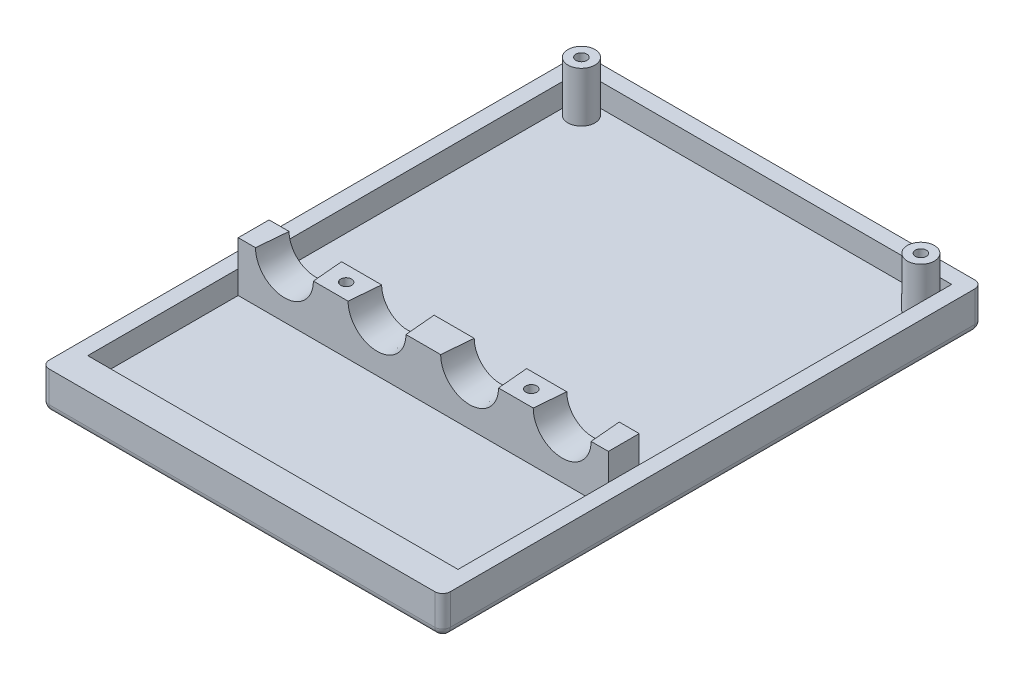
from build123d import *

# Parameters (mm, degrees)
SKETCH1_W                      = 82.55
SKETCH1_H                      = 111.125
BOSS_EXTRUDE1_DEPTH            = 7.9375
SKETCH3_W                      = 76.2
SKETCH3_H                      = 101.6
CUT_EXTRUDE1_DEPTH             = 4.7625
SKETCH4_R                      = 2.778125
SKETCH4_W                      = 76.2
SKETCH4_H                      = 6.35
BOSS_EXTRUDE2_DEPTH            = 4.7625
SKETCH5_R                      = 2.778125
SKETCH5_W                      = 76.1746
SKETCH5_H                      = 6.35
BOSS_EXTRUDE3_DEPTH            = 5.5499
SKETCH7_R                      = 5.953125
CUT_EXTRUDE2_DEPTH             = 6.35
CUT_EXTRUDE2_TAPER             = 5
FILLET1_R                      = 1.5875
SKETCH9_W                      = 0.693032722
SKETCH9_H                      = 1.166839696
CUT_EXTRUDE6_DEPTH             = 0.79375
SKETCH10_W                     = 1.300636175
SKETCH10_H                     = 0.609288305
BOSS_EXTRUDE10_DEPTH           = 0.79375
SKETCH10_W_2                   = 1.290786677
SKETCH10_H_2                   = 0.635299333
BOSS_EXTRUDE10_2_DEPTH         = 0.79375
SKETCH10_W_3                   = 0.590635344
SKETCH10_H_3                   = 1.200906415
BOSS_EXTRUDE10_3_DEPTH         = 0.79375
SKETCH10_W_4                   = 0.595847513
SKETCH10_H_4                   = 0.630493571
BOSS_EXTRUDE10_4_DEPTH         = 0.79375
F_4_40_TAPPED_HOLE4_AT_2_COUNT = 2
F_4_40_TAPPED_HOLE4_AT_2_PITCH = 38.1
F_4_40_TAPPED_HOLE4_AT_3_COUNT = 2
F_4_40_TAPPED_HOLE4_AT_3_PITCH = 83.946333536
F_4_40_TAPPED_HOLE4_AT_4_COUNT = 2
F_4_40_TAPPED_HOLE4_AT_4_PITCH = 66.22463223


with BuildPart() as part:
    # Sketch1 → Boss-Extrude1 (new body)
    with BuildSketch(Plane(origin=(0, 0, 0), x_dir=(1, 0, 0), z_dir=(0, 1, 0))):
        Rectangle(SKETCH1_W, SKETCH1_H)
    extrude(amount=BOSS_EXTRUDE1_DEPTH)

    # Sketch3 → Cut-Extrude1 (cut)
    with BuildSketch(Plane(origin=(0, 7.9375, 0), x_dir=(-1, 0, 0), z_dir=(0, 1, 0))):
        with Locations((0, -1.5875)):
            Rectangle(SKETCH3_W, SKETCH3_H)
    extrude(amount=-CUT_EXTRUDE1_DEPTH, mode=Mode.SUBTRACT)

    # Sketch4 → Boss-Extrude2 (add)
    with BuildSketch(Plane(origin=(0, 3.175, 0), x_dir=(-1, 0, 0), z_dir=(0, 1, 0))):
        with Locations((34.925, -49.2125)):
            Circle(SKETCH4_R)
        with Locations((-34.925, -49.2125)):
            Circle(SKETCH4_R)
        with Locations((0, 15.08125)):
            Rectangle(SKETCH4_W, SKETCH4_H)
    extrude(amount=BOSS_EXTRUDE2_DEPTH)

    # Sketch5 → Boss-Extrude3 (add)
    with BuildSketch(Plane(origin=(0, 7.9375, 0), x_dir=(-1, 0, 0), z_dir=(0, 1, 0))):
        with Locations((34.925, -49.2125)):
            Circle(SKETCH5_R)
        with Locations((-34.925, -49.2125)):
            Circle(SKETCH5_R)
        with Locations((0, 15.08125)):
            Rectangle(SKETCH5_W, SKETCH5_H)
    extrude(amount=BOSS_EXTRUDE3_DEPTH)

    # Sketch7 → Cut-Extrude2 (cut)
    with BuildSketch(Plane.XY.offset(18.25625)):
        with Locations((-28.575, 13.4874)):
            Circle(SKETCH7_R)
        with Locations((-9.525, 13.4874)):
            Circle(SKETCH7_R)
        with Locations((9.525, 13.4874)):
            Circle(SKETCH7_R)
        with Locations((28.575, 13.4874)):
            Circle(SKETCH7_R)
    extrude(amount=-CUT_EXTRUDE2_DEPTH, taper=CUT_EXTRUDE2_TAPER, mode=Mode.SUBTRACT)

    # Fillet1
    fillet1_edges = [part.edges().sort_by_distance(p)[0] for p in [
        (0, 0, 55.5625),
        (-41.275, 0, 0),
        (0, 0, -55.5625),
        (41.275, 0, 0),
        (41.275, 3.96875, 55.5625),
        (-41.275, 3.96875, 55.5625),
        (-41.275, 3.96875, -55.5625),
        (41.275, 3.96875, -55.5625),
    ]]
    fillet(fillet1_edges, radius=FILLET1_R)

    # Sketch9 → Cut-Extrude6 (cut)
    with BuildSketch(Plane.XZ):
        Polygon((-19.871599205, 50.060948489), (-23.378660117, 50.060948489), (-23.378660117, 49.462991256), (-24.789045709, 49.462991256), (-24.789045709, 50.060948489), (-28.298105511, 50.060948489), (-28.298105511, 49.462991256), (-30.146692, 49.462991256), (-30.146692, 48.220366501), (-30.824259295, 48.220366501), (-30.824259295, 47.536075665), (-31.942026377, 47.536075665), (-31.942026377, 46.362512428), (-32.668484568, 46.362512428), (-32.668484568, 45.726930772), (-33.201923216, 45.726930772), (-33.201923216, 43.240218584), (-33.777165784, 43.240218584), (-33.777165784, 42.020126776), (-36.257517866, 42.020126776), (-36.257517866, 41.524130834), (-36.88782972, 41.524130834), (-36.88782972, 37.820052598), (-36.257517866, 37.820052598), (-36.257517866, 37.33532313), (-34.485815679, 37.33532313), (-34.485815679, 32.3250012), (-33.777165784, 32.3250012), (-33.777165784, 31.694507629), (-33.201923216, 31.694507629), (-33.201923216, 30.527667933), (-31.942026377, 30.527667933), (-31.942026377, 29.314299666), (-32.571974796, 29.314299666), (-32.571974796, 27.461170243), (-33.201923216, 27.461170243), (-33.201923216, 26.338133359), (-30.824259295, 26.338133359), (-30.824259295, 27.469347523), (-30.146692, 27.469347523), (-30.146692, 28.091746255), (-29.598741686, 28.091746255), (-29.598741686, 27.469347523), (-28.909041959, 27.469347523), (-28.909041959, 26.903740441), (-28.298105511, 26.903740441), (-28.298105511, 25.633141775), (-25.910537024, 25.633141775), (-25.910537024, 25.075738158), (-22.795572643, 25.075738158), (-22.795572643, 25.633141775), (-20.371967068, 25.633141775), (-20.371967068, 26.268441108), (-19.871599205, 26.268441108), (-19.871599205, 26.903740441), (-19.082474376, 26.903740441), (-19.082474376, 27.469347523), (-17.993013222, 27.469347523), (-17.993013222, 26.268441108), (-16.088645027, 26.268441108), (-16.088645027, 29.314299666), (-16.665655943, 29.314299666), (-16.665655943, 30.527667933), (-14.850892856, 30.527667933), (-14.850892856, 32.3250012), (-14.251854017, 32.3250012), (-14.251854017, 35.994775983), (-13.658395717, 35.994775983), (-13.658395717, 37.33532313), (-11.8843629, 37.33532313), (-11.8843629, 37.820052598), (-11.280195998, 37.820052598), (-11.280195998, 41.524130834), (-11.8843629, 41.524130834), (-11.8843629, 42.020126776), (-14.251854017, 42.020126776), (-14.251854017, 43.240218584), (-14.850892856, 43.240218584), (-14.850892856, 45.726930772), (-15.433476892, 45.726930772), (-15.433476892, 46.362512428), (-16.088645027, 46.362512428), (-16.088645027, 47.536075665), (-17.299980501, 47.536075665), (-17.299980501, 48.220366501), (-17.993013222, 48.220366501), (-17.993013222, 49.462991256), (-19.871599205, 49.462991256), align=None)
        Polygon((-16.665655943, 42.663637575), (-17.993013222, 42.663637575), (-17.993013222, 43.240218584), (-19.871599205, 43.240218584), (-19.871599205, 43.83259077), (-21.599961018, 43.83259077), (-21.599961018, 43.240218584), (-22.204937299, 43.240218584), (-22.204937299, 42.663637575), (-22.795572643, 42.663637575), (-22.795572643, 41.524130834), (-25.230484206, 41.524130834), (-25.230484206, 42.663637575), (-25.910537024, 42.663637575), (-25.910537024, 43.240218584), (-26.562769367, 43.240218584), (-26.562769367, 43.83259077), (-28.298105511, 43.83259077), (-28.298105511, 43.240218584), (-30.146692, 43.240218584), (-30.146692, 42.663637575), (-31.444814914, 42.663637575), (-31.444814914, 41.524130834), (-31.942026377, 41.524130834), (-31.942026377, 40.922626367), (-32.668484568, 40.922626367), (-32.668484568, 38.461072219), (-31.942026377, 38.461072219), (-31.942026377, 37.820052598), (-30.795753457, 37.820052598), (-30.795753457, 37.33532313), (-30.146692, 37.33532313), (-30.146692, 37.820052598), (-25.910537024, 37.820052598), (-25.910537024, 38.461072219), (-22.204937299, 38.461072219), (-22.204937299, 37.820052598), (-17.993013222, 37.820052598), (-17.993013222, 37.33532313), (-17.299980501, 37.33532313), (-17.299980501, 37.820052598), (-16.088645027, 37.820052598), (-16.088645027, 38.461072219), (-15.433476892, 38.461072219), (-15.433476892, 40.922626367), (-16.088645027, 40.922626367), (-16.088645027, 41.524130834), (-16.665655943, 41.524130834), align=None, mode=Mode.SUBTRACT)
        Polygon((-21.015392045, 47.536075665), (-21.015392045, 46.362512428), (-21.599961018, 46.362512428), (-21.599961018, 45.726930772), (-26.562769367, 45.726930772), (-26.562769367, 46.362512428), (-27.120021669, 46.362512428), (-27.120021669, 47.536075665), (-26.562769367, 47.536075665), (-26.562769367, 46.949294047), (-25.910537024, 46.949294047), (-25.910537024, 46.362512428), (-22.204937299, 46.362512428), (-22.204937299, 46.949294047), (-21.599961018, 46.949294047), (-21.599961018, 47.536075665), align=None, mode=Mode.SUBTRACT)
        with Locations((-17.646496862, 31.111087781)):
            Rectangle(SKETCH9_W, SKETCH9_H, mode=Mode.SUBTRACT)
        Polygon((-18.588860736, 32.3250012), (-18.588860736, 33.032386042), (-19.082474376, 33.032386042), (-19.082474376, 34.223490871), (-20.371967068, 34.223490871), (-20.371967068, 35.455360662), (-21.015392045, 35.455360662), (-21.015392045, 35.994775983), (-22.795572643, 35.994775983), (-22.795572643, 36.604643891), (-25.910537024, 36.604643891), (-25.910537024, 35.994775983), (-27.120021669, 35.994775983), (-27.120021669, 35.455360662), (-28.298105511, 35.455360662), (-28.298105511, 34.223490871), (-28.909041959, 34.223490871), (-28.909041959, 33.032386042), (-28.298105511, 33.032386042), (-28.298105511, 33.627938457), (-27.120021669, 33.627938457), (-27.120021669, 34.839425767), (-26.515279346, 34.839425767), (-26.515279346, 34.233682112), (-25.230484206, 34.233682112), (-25.230484206, 35.455360662), (-24.789045709, 35.455360662), (-24.789045709, 34.233682112), (-24.032657154, 34.233682112), (-24.032657154, 35.455360662), (-22.795572643, 35.455360662), (-22.795572643, 34.233682112), (-22.204937299, 34.233682112), (-22.204937299, 35.455360662), (-21.599961018, 35.455360662), (-21.599961018, 34.844521387), (-21.015392045, 34.844521387), (-21.015392045, 33.627938457), (-20.371967068, 33.627938457), (-20.371967068, 32.3250012), align=None, mode=Mode.SUBTRACT)
        Polygon((-20.465409799, 29.314299666), (-20.465409799, 27.469347523), (-22.204937299, 27.469347523), (-22.204937299, 29.314299666), (-22.795572643, 29.314299666), (-22.795572643, 29.963205459), (-21.015392045, 29.963205459), (-21.015392045, 29.314299666), align=None, mode=Mode.SUBTRACT)
        Polygon((-24.789045709, 26.268441108), (-24.789045709, 27.469347523), (-25.910537024, 27.469347523), (-25.910537024, 26.868894315), (-25.349791366, 26.868894315), (-25.349791366, 26.268441108), align=None, mode=Mode.SUBTRACT)
        Polygon((-25.230484206, 29.880011412), (-25.230484206, 29.314299666), (-26.515279346, 29.314299666), (-26.515279346, 28.70103456), (-28.298105511, 28.70103456), (-28.298105511, 29.314299666), (-27.120021669, 29.314299666), (-27.120021669, 29.880011412), align=None, mode=Mode.SUBTRACT)
        Polygon((-17.299980501, 38.461072219), (-19.871599205, 38.461072219), (-19.871599205, 39.056223244), (-20.371967068, 39.056223244), (-20.371967068, 39.674178437), (-21.015392045, 39.674178437), (-21.015392045, 40.292097217), (-21.599961018, 40.292097217), (-21.599961018, 41.524130834), (-21.015392045, 41.524130834), (-21.015392045, 42.020126776), (-19.192707944, 42.020126776), (-19.192707944, 41.524130834), (-17.993013222, 41.524130834), (-17.993013222, 40.292097217), (-17.299980501, 40.292097217), align=None)
        Polygon((-26.562769367, 41.524130834), (-26.562769367, 40.292097217), (-27.120021669, 40.292097217), (-27.120021669, 39.674178437), (-27.737946518, 39.674178437), (-27.737946518, 39.056223244), (-28.298105511, 39.056223244), (-28.298105511, 38.461072219), (-30.795753457, 38.461072219), (-30.795753457, 40.292097217), (-30.146692, 40.292097217), (-30.146692, 41.524130834), (-28.909041959, 41.524130834), (-28.909041959, 42.143492776), (-27.120021669, 42.143492776), (-27.120021669, 41.524130834), align=None)
    extrude(amount=-CUT_EXTRUDE6_DEPTH, mode=Mode.SUBTRACT)

    # Sketch26 → #4-40 Tapped Hole4 (revolve, cut)
    with BuildSketch(Plane(origin=(19.05, 13.4874, 15.08125), x_dir=(0, 0, 1), z_dir=(1, 0, 0))):
        Polygon((0, 0), (0, 6.267152758), (1.1303, 5.588), (1.1303, 0), align=None)
    f_4_40_tapped_hole4 = revolve(axis=Axis((19.05, 19.8374, 15.08125), (0, -1, 0)), mode=Mode.SUBTRACT)

    # #4-40 Tapped Hole4 at 2: #4-40 Tapped Hole4 ×2
    with Locations(*[(-i * F_4_40_TAPPED_HOLE4_AT_2_PITCH, 0, 0) for i in range(1, F_4_40_TAPPED_HOLE4_AT_2_COUNT)]):
        add(f_4_40_tapped_hole4, mode=Mode.SUBTRACT)

    # #4-40 Tapped Hole4 at 3: #4-40 Tapped Hole4 ×2
    with Locations(*[Vector(-0.642970309, 0, -0.765891103) * (i * F_4_40_TAPPED_HOLE4_AT_3_PITCH) for i in range(1, F_4_40_TAPPED_HOLE4_AT_3_COUNT)]):
        add(f_4_40_tapped_hole4, mode=Mode.SUBTRACT)

    # #4-40 Tapped Hole4 at 4: #4-40 Tapped Hole4 ×2
    with Locations(*[Vector(0.23971443, 0, -0.970843444) * (i * F_4_40_TAPPED_HOLE4_AT_4_PITCH) for i in range(1, F_4_40_TAPPED_HOLE4_AT_4_COUNT)]):
        add(f_4_40_tapped_hole4, mode=Mode.SUBTRACT)


with BuildPart() as body_2:
    # Sketch10 → Boss-Extrude10 (new body)
    with BuildSketch(Plane.XZ.offset(-0.79375)):
        with Locations((-28.948423598, 28.396390408)):
            Rectangle(SKETCH10_W, SKETCH10_H)
    extrude(amount=BOSS_EXTRUDE10_DEPTH)


with BuildPart() as body_3:
    # Sketch10 → Boss-Extrude10 2 (new body)
    with BuildSketch(Plane.XZ.offset(-0.79375)):
        with Locations((-23.440965981, 25.950791442)):
            Rectangle(SKETCH10_W_2, SKETCH10_H_2)
    extrude(amount=BOSS_EXTRUDE10_2_DEPTH)


with BuildPart() as body_4:
    # Sketch10 → Boss-Extrude10 3 (new body)
    with BuildSketch(Plane.XZ.offset(-0.79375)):
        with Locations((-22.500254971, 26.868894316)):
            Rectangle(SKETCH10_W_3, SKETCH10_H_3)
    extrude(amount=BOSS_EXTRUDE10_3_DEPTH)


with BuildPart() as body_5:
    # Sketch10 → Boss-Extrude10 4 (new body)
    with BuildSketch(Plane.XZ.offset(-0.79375)):
        with Locations((-18.29093698, 32.009754415)):
            Rectangle(SKETCH10_W_4, SKETCH10_H_4)
    extrude(amount=BOSS_EXTRUDE10_4_DEPTH)


solid = Compound([part.part, body_2.part, body_3.part, body_4.part, body_5.part])
